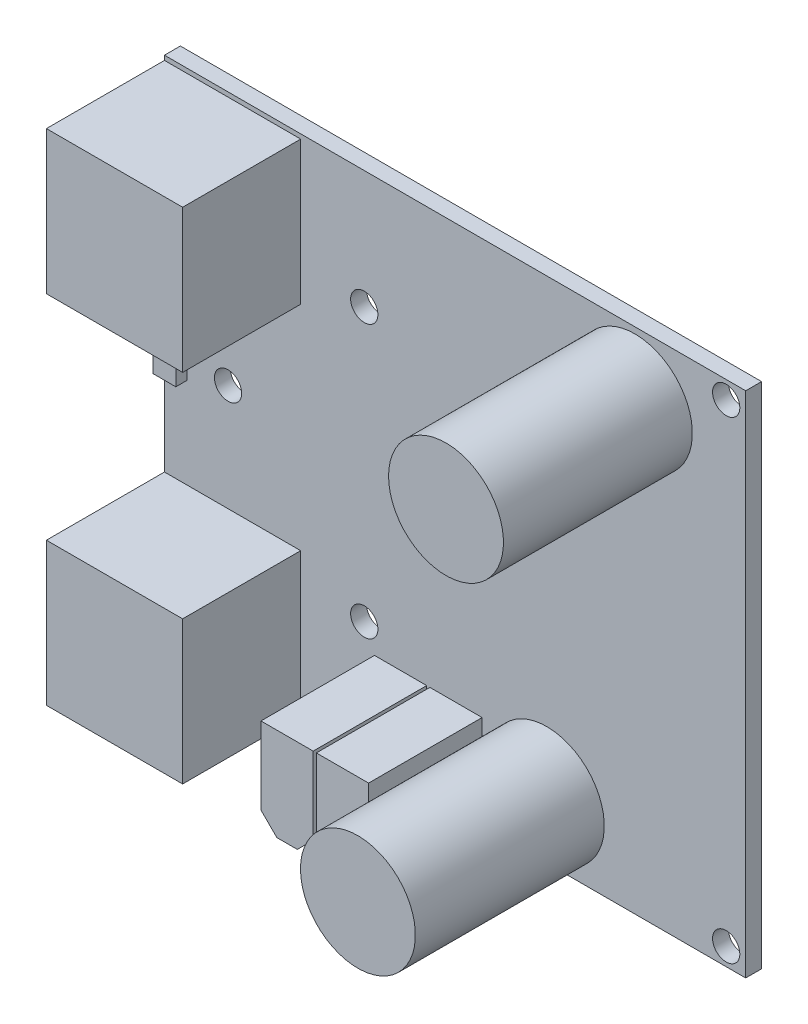
from build123d import *

# Parameters (mm, degrees)
SKETCH1_W                 = 64
SKETCH1_H                 = 56
BOSS_EXTRUDE1_DEPTH       = 1.75
SKETCH2_W                 = 5.6
SKETCH2_H                 = 8
BOSS_EXTRUDE2_DEPTH       = 3.249999999
BOSS_EXTRUDE3_DEPTH       = 12.5
SKETCH4_W                 = 2.5
SKETCH4_H                 = 3.249999996
BOSS_EXTRUDE4_DEPTH       = 1.250000001
SKETCH5_W                 = 15
SKETCH5_H                 = 15.750000006
BOSS_EXTRUDE5_DEPTH       = 12.999999998
SKETCH6_W                 = 15
SKETCH6_H                 = 15.749999994
BOSS_EXTRUDE6_DEPTH       = 13
BOSS_EXTRUDE7_DEPTH       = 12.5
SKETCH8_W                 = 6.5
SKETCH8_H                 = 6.499999992
BOSS_EXTRUDE8_DEPTH       = 1.9
SKETCH9_W                 = 6.325
SKETCH9_H                 = 20.8
SKETCH10_W                = 6.325
SKETCH10_H                = 20.8
F_3_CLEARANCE_HOLE1_D     = 3
F_3_CLEARANCE_HOLE1_DEPTH = 22.55


with BuildPart() as part:
    # Sketch1 → Boss-Extrude1 (new body)
    with BuildSketch(Plane(origin=(0, 0, 9.525), x_dir=(-1, 0, 0), z_dir=(0, 0, -1))):
        with Locations((-70.325, 0)):
            Rectangle(SKETCH1_W, SKETCH1_H)
    extrude(amount=-BOSS_EXTRUDE1_DEPTH)

    # Sketch2 → Boss-Extrude2 (add)
    with BuildSketch(Plane.XY.offset(11.275)):
        with Locations((39.625, 6.2)):
            Rectangle(SKETCH2_W, SKETCH2_H)
    extrude(amount=BOSS_EXTRUDE2_DEPTH)

    # Sketch3 → Boss-Extrude3 (add)
    with BuildSketch(Plane.XY.offset(11.275)):
        Polygon((61.45, -17.675), (67.199999996, -17.675), (67.199999996, -26.174999992), (65.449999996, -27.924999992), (63.2, -27.924999992), (61.45, -26.174999992), align=None)
    extrude(amount=BOSS_EXTRUDE3_DEPTH)

    # Sketch4 → Boss-Extrude4 (add)
    with BuildSketch(Plane.XY.offset(11.275)):
        with Locations((39.575, -0.125000002)):
            Rectangle(SKETCH4_W, SKETCH4_H)
    extrude(amount=BOSS_EXTRUDE4_DEPTH)

    # Sketch5 → Boss-Extrude5 (add)
    with BuildSketch(Plane.XY.offset(11.275)):
        with Locations((45.825, -19.625000009)):
            Rectangle(SKETCH5_W, SKETCH5_H)
    extrude(amount=BOSS_EXTRUDE5_DEPTH)

    # Sketch6 → Boss-Extrude6 (add)
    with BuildSketch(Plane.XY.offset(11.275)):
        with Locations((45.825, 19.625000009)):
            Rectangle(SKETCH6_W, SKETCH6_H)
    extrude(amount=BOSS_EXTRUDE6_DEPTH)

    # Sketch7 → Boss-Extrude7 (add)
    with BuildSketch(Plane.XY.offset(11.275)):
        Polygon((67.55, -17.675), (73.299999996, -17.675), (73.299999996, -26.174999992), (71.549999996, -27.924999992), (69.3, -27.924999992), (67.55, -26.174999992), align=None)
    extrude(amount=BOSS_EXTRUDE7_DEPTH)

    # Sketch8 → Boss-Extrude8 (add)
    with BuildSketch(Plane(origin=(0, 0, 9.525), x_dir=(-1, 0, 0), z_dir=(0, 0, -1))):
        with Locations((-60.325, 0)):
            Rectangle(SKETCH8_W, SKETCH8_H)
    extrude(amount=BOSS_EXTRUDE8_DEPTH)

    # Sketch9 → Revolve1 (revolve)
    with BuildSketch(Plane.XZ.offset(21.3)):
        with Locations((83.5875, 21.675)):
            Rectangle(SKETCH9_W, SKETCH9_H)
    revolve(axis=Axis((80.425, -21.3, 32.075), (0, 0, -1)))

    # Sketch10 → Revolve2 (revolve)
    with BuildSketch(Plane.XZ.offset(-21)):
        with Locations((93.2875, 21.675)):
            Rectangle(SKETCH10_W, SKETCH10_H)
    revolve(axis=Axis((90.125, 21, 32.075), (0, 0, -1)))

    # #3 Clearance Hole1
    with Locations(Plane(origin=(0, 0, 9.525), x_dir=(-1, 0, 0), z_dir=(0, 0, -1))):
        with Locations((-45.325, 0), (-60.325, 15), (-75.325, 0), (-60.325, -15), (-100.175, 26.05), (-100.175, -26.05)):
            Hole(F_3_CLEARANCE_HOLE1_D / 2, depth=F_3_CLEARANCE_HOLE1_DEPTH)


solid = part.part
